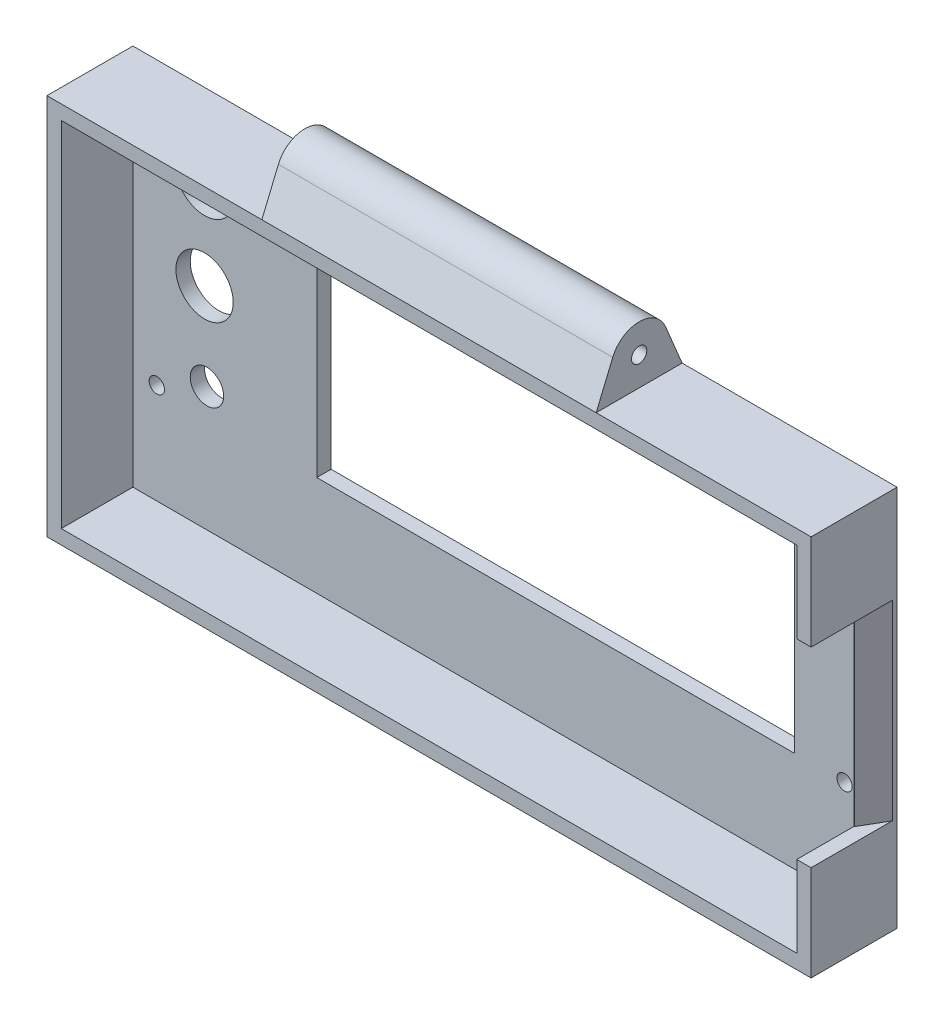
from build123d import *

# Parameters (mm, degrees)
ESBO_O2_W                = 18
ESBO_O2_H                = 80
RESSALTO_EXTRUS_O1_DEPTH = 80
CASCA1_T                 = -3
ESBO_O4_R                = 1.6
ESBO_O4_R_2              = 6
ESBO_O4_R_3              = 3.5
ESBO_O4_R_4              = 6.25
ESBO_O4_W                = 100
ESBO_O4_H                = 40
CORTE_EXTRUS_O1_DEPTH    = 3
ESBO_O5_R                = 1.6
RESSALTO_EXTRUS_O2_DEPTH = 160
ESBO_O6_W                = 45
ESBO_O6_H                = 12
CORTE_EXTRUS_O2_DEPTH    = 19
ESBO_O7_W                = 12
ESBO_O7_H                = 40
CORTE_EXTRUS_O3_DEPTH    = 10
CHANFRO1_SIZE            = 5
CHANFRO1_SIZE2           = 2.886751346


with BuildPart() as part:
    # Esboço2 → Ressalto-extrusão1 (new body, symmetric)
    with BuildSketch(Plane(origin=(0, 0, 0), x_dir=(0, 0, -1), z_dir=(1, 0, 0))):
        with Locations((9, 40)):
            Rectangle(ESBO_O2_W, ESBO_O2_H)
    extrude(amount=RESSALTO_EXTRUS_O1_DEPTH, both=True)

    # Casca1
    casca1_openings = [part.faces().sort_by_distance(p)[0] for p in [
        (0, 40, 0),
    ]]
    offset(amount=CASCA1_T, openings=casca1_openings, kind=Kind.INTERSECTION)

    # Esboço4 → Corte-extrusão1 (cut)
    with BuildSketch(Plane(origin=(0, 0, -18), x_dir=(1, 0, 0), z_dir=(0, 0, -1))):
        with Locations((-72, -24)):
            Circle(ESBO_O4_R)
        with Locations((-72, -73)):
            Circle(ESBO_O4_R)
        with Locations((72, -73)):
            Circle(ESBO_O4_R)
        with Locations((72, -24)):
            Circle(ESBO_O4_R)
        with Locations((-62, -47)):
            Circle(ESBO_O4_R_2)
        with Locations((-61.5, -29)):
            Circle(ESBO_O4_R_3)
        with Locations((-62, -66)):
            Circle(ESBO_O4_R_4)
        with Locations((11.5, -44)):
            Rectangle(ESBO_O4_W, ESBO_O4_H)
    extrude(amount=-CORTE_EXTRUS_O1_DEPTH, mode=Mode.SUBTRACT)

    # Esboço5 → Ressalto-extrusão2 (add, through all)
    with BuildSketch(Plane(origin=(80, 0, 0), x_dir=(0, 0, -1), z_dir=(1, 0, 0))):
        with BuildLine():
            Line((14.538461538, 88.307692308), (18, 80))
            Line((18, 80), (0, 80))
            Line((0, 80), (3.461538462, 88.307692308))
            ThreePointArc((3.461538462, 88.307692308), (9, 92), (14.538461538, 88.307692308))
        make_face()
        with Locations((9, 86)):
            Circle(ESBO_O5_R, mode=Mode.SUBTRACT)
    extrude(amount=-RESSALTO_EXTRUS_O2_DEPTH)

    # Esboço6 → Corte-extrusão2 (cut, through all)
    with BuildSketch(Plane(origin=(0, 0, -18), x_dir=(-1, 0, 0), z_dir=(0, 0, -1))):
        with Locations((-57.5, 86)):
            Rectangle(ESBO_O6_W, ESBO_O6_H)
        with Locations((57.5, 86)):
            Rectangle(ESBO_O6_W, ESBO_O6_H)
    extrude(amount=-CORTE_EXTRUS_O2_DEPTH, mode=Mode.SUBTRACT)

    # Esboço7 → Corte-extrusão3 (cut)
    with BuildSketch(Plane(origin=(80, 0, 0), x_dir=(0, 0, -1), z_dir=(1, 0, 0))):
        with Locations((6, 40)):
            Rectangle(ESBO_O7_W, ESBO_O7_H)
    extrude(amount=-CORTE_EXTRUS_O3_DEPTH, mode=Mode.SUBTRACT)

    # Chanfro1
    chanfro1_edges = [part.edges().sort_by_distance(p)[0] for p in [
        (80, 40, -12),
    ]]
    chanfro1_side = [part.faces().sort_by_distance(p)[0] for p in [
        (80, 79.18, -9),
    ]]
    chamfer(chanfro1_edges, length=CHANFRO1_SIZE, length2=CHANFRO1_SIZE2, reference=chanfro1_side[0])


solid = part.part
